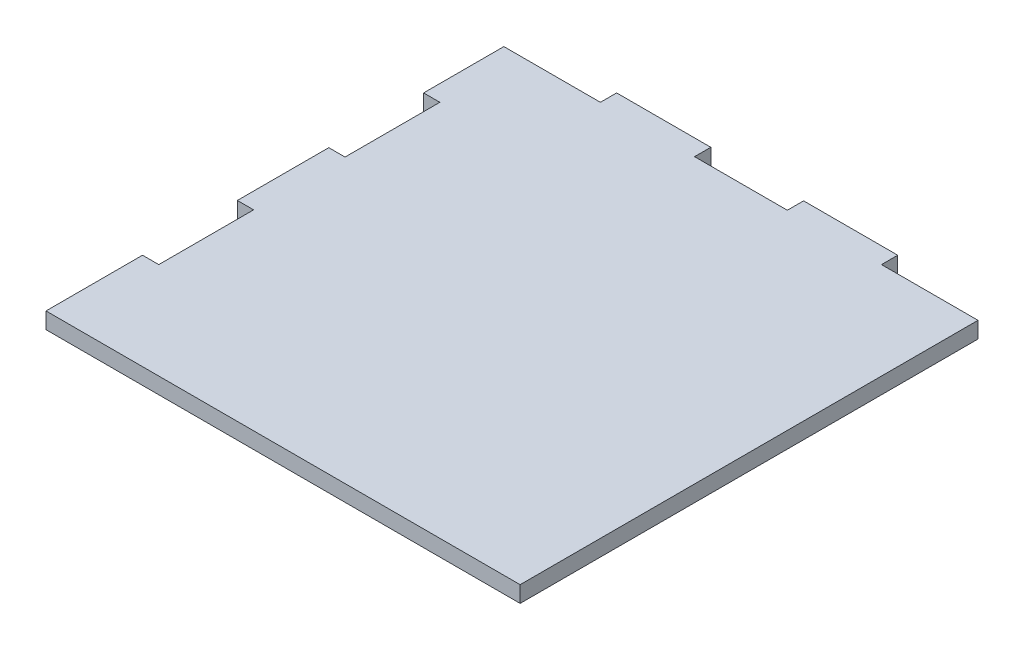
from build123d import *

# Parameters (mm, degrees)
BOSS_EXTRUDE1_DEPTH = 12


with BuildPart() as part:
    # Sketch1 → Boss-Extrude1 (new body)
    with BuildSketch(Plane(origin=(0, 0, 0), x_dir=(1, 0, 0), z_dir=(0, 1, 0))):
        Polygon((209.25, 350), (278.75, 350), (278.75, 338), (350, 338), (350, 0), (0, 0), (0, 71.25), (12, 71.25), (12, 141.25), (0, 141.25), (0, 208.75), (12, 208.75), (12, 278.75), (0, 278.75), (0, 338), (71.25, 338), (71.25, 350), (140.75, 350), (140.75, 338), (209.25, 338), align=None)
    extrude(amount=BOSS_EXTRUDE1_DEPTH)


solid = part.part
